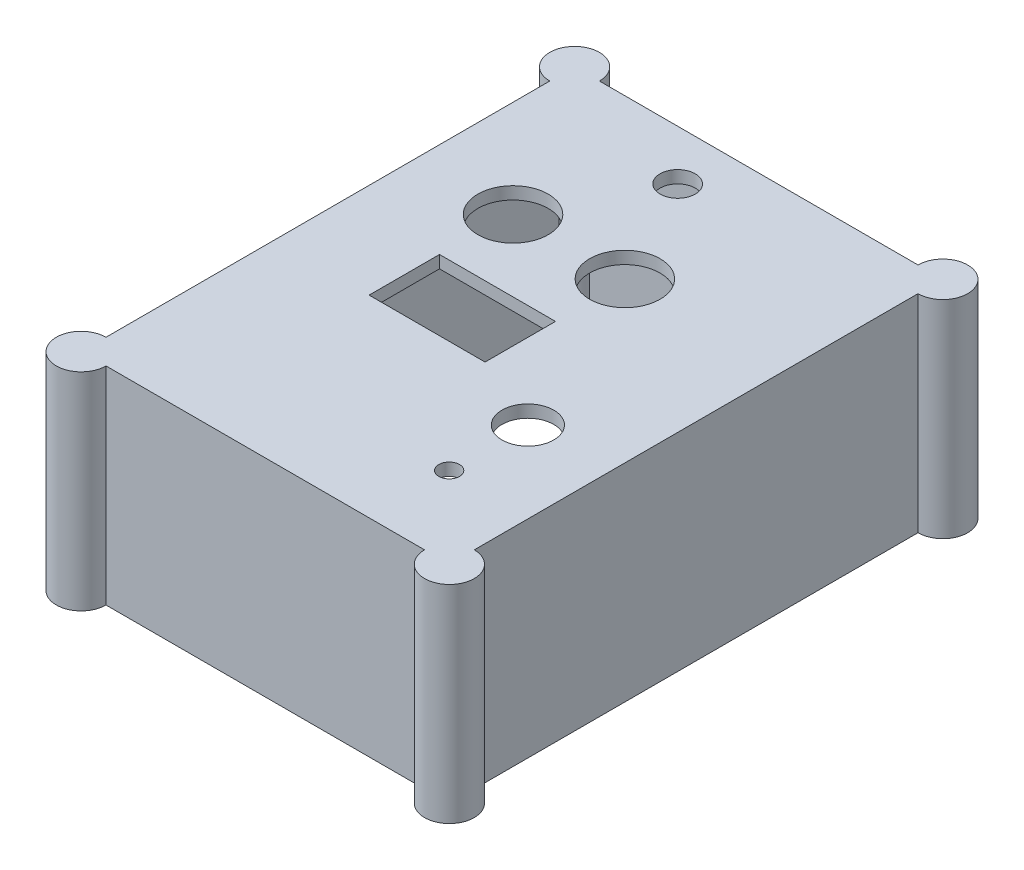
from build123d import *

# Parameters (mm, degrees)
SKETCH1_W           = 85
SKETCH1_H           = 115
SKETCH1_R           = 4.25
SKETCH1_R_2         = 8.5
SKETCH1_R_3         = 6.25
SKETCH1_R_4         = 2.5
SKETCH1_W_2         = 28
SKETCH1_H_2         = 17
BOSS_EXTRUDE1_DEPTH = 3
SKETCH2_W           = 88.917707464
SKETCH2_H           = 119.141928202
SKETCH2_W_2         = 85
SKETCH2_H_2         = 115
BOSS_EXTRUDE2_DEPTH = 50
SKETCH3_R           = 6
BOSS_EXTRUDE3_DEPTH = 50
SKETCH5_R           = 1.6
CUT_EXTRUDE1_DEPTH  = 30


with BuildPart() as part:
    # Sketch1 → Boss-Extrude1 (new body)
    with BuildSketch(Plane(origin=(0, 0, 0), x_dir=(1, 0, 0), z_dir=(0, 1, 0))):
        Rectangle(SKETCH1_W, SKETCH1_H)
        with Locations((-7.5, 47.5)):
            Circle(SKETCH1_R, mode=Mode.SUBTRACT)
        with Locations((-21, 21.25)):
            Circle(SKETCH1_R_2, mode=Mode.SUBTRACT)
        with Locations((6, 21.25)):
            Circle(SKETCH1_R_2, mode=Mode.SUBTRACT)
        with Locations((24.83030278, -21)):
            Circle(SKETCH1_R_3, mode=Mode.SUBTRACT)
        with Locations((24.83030278, -40)):
            Circle(SKETCH1_R_4, mode=Mode.SUBTRACT)
        with Locations((-7.5, -4.5)):
            Rectangle(SKETCH1_W_2, SKETCH1_H_2, mode=Mode.SUBTRACT)
    extrude(amount=BOSS_EXTRUDE1_DEPTH)

    # Sketch2 → Boss-Extrude2 (add)
    with BuildSketch(Plane(origin=(0, 3, 0), x_dir=(1, 0, 0), z_dir=(0, 1, 0))):
        Rectangle(SKETCH2_W, SKETCH2_H)
        Rectangle(SKETCH2_W_2, SKETCH2_H_2, mode=Mode.SUBTRACT)
    extrude(amount=-BOSS_EXTRUDE2_DEPTH)

    # Sketch3 → Boss-Extrude3 (add)
    with BuildSketch(Plane(origin=(0, 3, 0), x_dir=(1, 0, 0), z_dir=(0, 1, 0))):
        with Locations((44.458853732, 59.570964101)):
            Circle(SKETCH3_R)
        with Locations((-44.458853732, 59.570964101)):
            Circle(SKETCH3_R)
        with Locations((44.458853732, -59.570964101)):
            Circle(SKETCH3_R)
        with Locations((-44.458853732, -59.570964101)):
            Circle(SKETCH3_R)
    extrude(amount=-BOSS_EXTRUDE3_DEPTH)

    # Sketch5 → Cut-Extrude1 (cut)
    with BuildSketch(Plane.XZ.offset(47)):
        with Locations((-44.458853732, 59.570964101)):
            Circle(SKETCH5_R)
        with Locations((44.458853732, 59.570964101)):
            Circle(SKETCH5_R)
        with Locations((44.458853732, -59.570964101)):
            Circle(SKETCH5_R)
        with Locations((-44.458853732, -59.570964101)):
            Circle(SKETCH5_R)
    extrude(amount=-CUT_EXTRUDE1_DEPTH, mode=Mode.SUBTRACT)


solid = part.part
